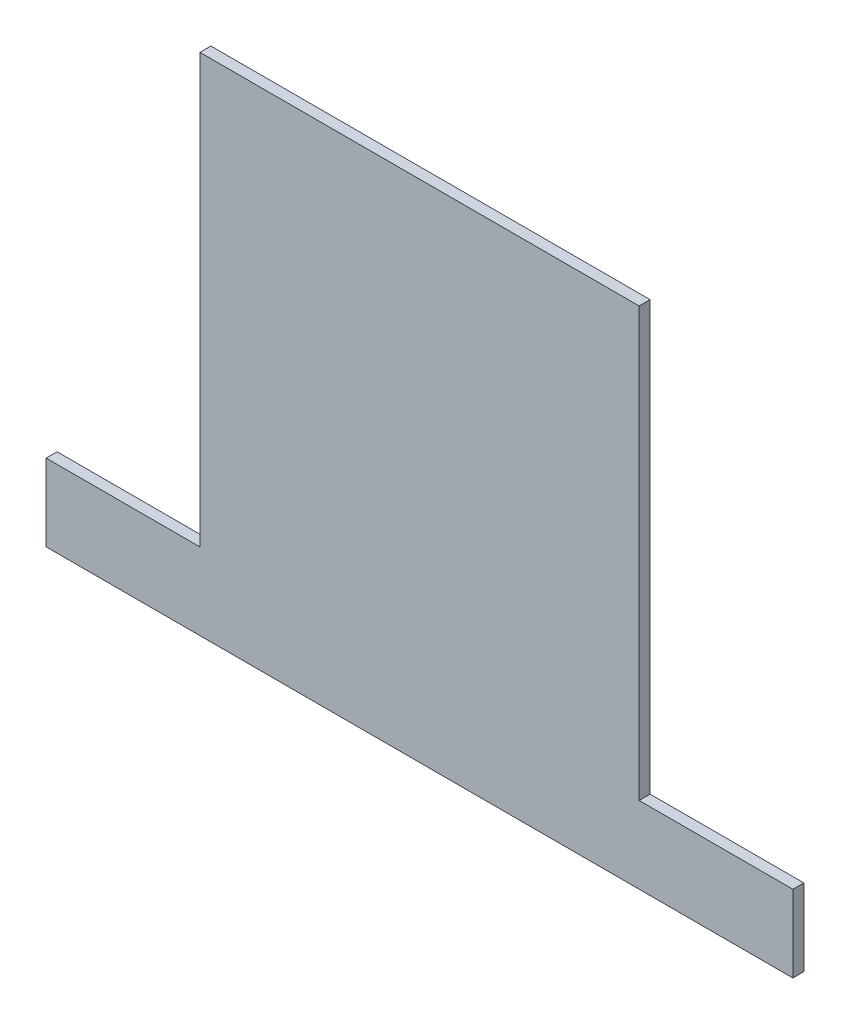
from build123d import *

# Parameters (mm, degrees)
SKETCH1_W           = 431.8
SKETCH1_H           = 292.1
BOSS_EXTRUDE1_DEPTH = 6.35
SKETCH2_W           = 88.9
SKETCH2_H           = 247.65
CUT_EXTRUDE1_DEPTH  = 7.35


with BuildPart() as part:
    # Sketch1 → Boss-Extrude1 (new body)
    with BuildSketch(Plane.XY):
        with Locations((215.9, 146.05)):
            Rectangle(SKETCH1_W, SKETCH1_H)
    extrude(amount=BOSS_EXTRUDE1_DEPTH)

    # Sketch2 → Cut-Extrude1 (cut, through all)
    with BuildSketch(Plane.XY.offset(6.35)):
        with Locations((44.45, 168.275)):
            Rectangle(SKETCH2_W, SKETCH2_H)
        with Locations((387.35, 168.275)):
            Rectangle(SKETCH2_W, SKETCH2_H)
    extrude(amount=-CUT_EXTRUDE1_DEPTH, mode=Mode.SUBTRACT)


solid = part.part
